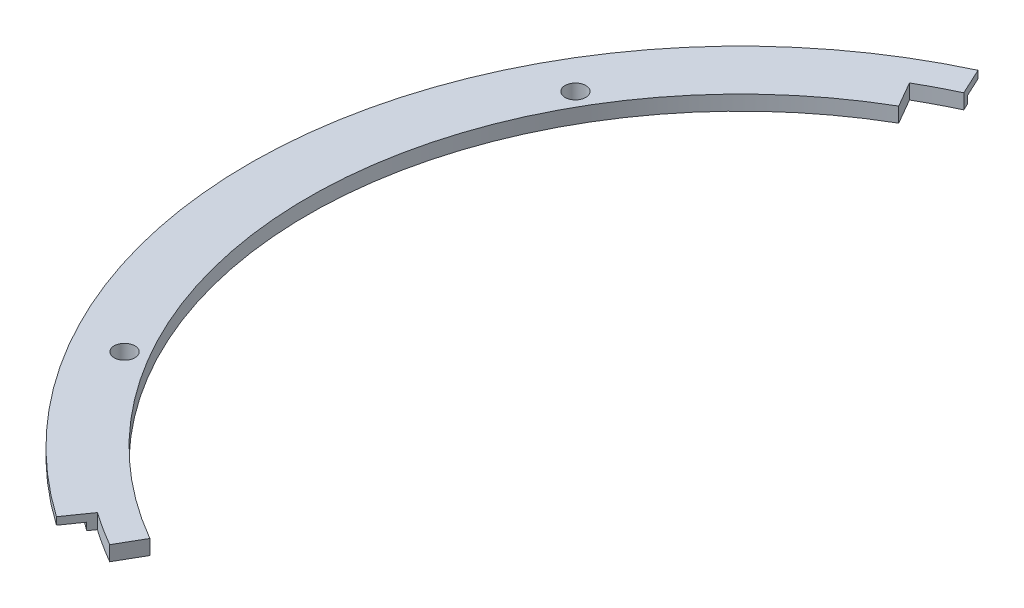
from build123d import *

# Parameters (mm, degrees)
SKETCH1_R           = 160.85
SKETCH1_R_2         = 3.556
SKETCH1_R_3         = 148.15
BOSS_EXTRUDE1_DEPTH = 5.08
SKETCH2_R           = 168.275
SKETCH2_R_2         = 160.85
BOSS_EXTRUDE2_DEPTH = 2.54
CUT_EXTRUDE1_DEPTH  = 6.08


with BuildPart() as part:
    # Sketch1 → Boss-Extrude1 (new body)
    with BuildSketch(Plane(origin=(0, 0, 0), x_dir=(1, 0, 0), z_dir=(0, 1, 0))):
        Circle(SKETCH1_R)
        with Locations((0, 154.5)):
            Circle(SKETCH1_R_2, mode=Mode.SUBTRACT)
        with Locations((133.800924885, 77.25)):
            Circle(SKETCH1_R_2, mode=Mode.SUBTRACT)
        with Locations((133.800924885, -77.25)):
            Circle(SKETCH1_R_2, mode=Mode.SUBTRACT)
        with Locations((0, -154.5)):
            Circle(SKETCH1_R_2, mode=Mode.SUBTRACT)
        with Locations((-133.800924885, -77.25)):
            Circle(SKETCH1_R_2, mode=Mode.SUBTRACT)
        with Locations((-133.800924885, 77.25)):
            Circle(SKETCH1_R_2, mode=Mode.SUBTRACT)
        Circle(SKETCH1_R_3, mode=Mode.SUBTRACT)
    extrude(amount=BOSS_EXTRUDE1_DEPTH)

    # Sketch2 → Boss-Extrude2 (add)
    with BuildSketch(Plane(origin=(0, 5.08, 0), x_dir=(1, 0, 0), z_dir=(0, 1, 0))):
        Circle(SKETCH2_R)
        Circle(SKETCH2_R_2, mode=Mode.SUBTRACT)
    extrude(amount=-BOSS_EXTRUDE2_DEPTH)

    # Sketch3 → Cut-Extrude1 (cut, through all)
    with BuildSketch(Plane(origin=(0, 5.08, 0), x_dir=(1, 0, 0), z_dir=(0, 1, 0))):
        with BuildLine():
            Line((-88.9, 153.979316793), (-84.1375, 145.730424822))
            ThreePointArc((-84.1375, 145.730424822), (-77.700747892, 149.261747953), (-71.116087994, 152.508942864))
            Line((-71.116087994, 152.508942864), (-66.863491736, 143.389220757))
            ThreePointArc((-66.863491736, 143.389220757), (-73.054402471, 140.336201444), (-79.10625, 137.016044196))
            Line((-79.10625, 137.016044196), (0, 0))
            Line((0, 0), (-79.10625, -137.016044196))
            ThreePointArc((-79.10625, -137.016044196), (-85.007514286, -133.435069121), (-90.746961936, -129.600092807))
            Line((-90.746961936, -129.600092807), (-96.518574827, -137.842810253))
            ThreePointArc((-96.518574827, -137.842810253), (-90.414091595, -141.921695544), (-84.1375, -145.730424822))
            Line((-84.1375, -145.730424822), (-88.9, -153.979316793))
            ThreePointArc((-88.9, -153.979316793), (177.8, 0), (-88.9, 153.979316793))
        make_face()
    extrude(amount=-CUT_EXTRUDE1_DEPTH, mode=Mode.SUBTRACT)


solid = part.part
